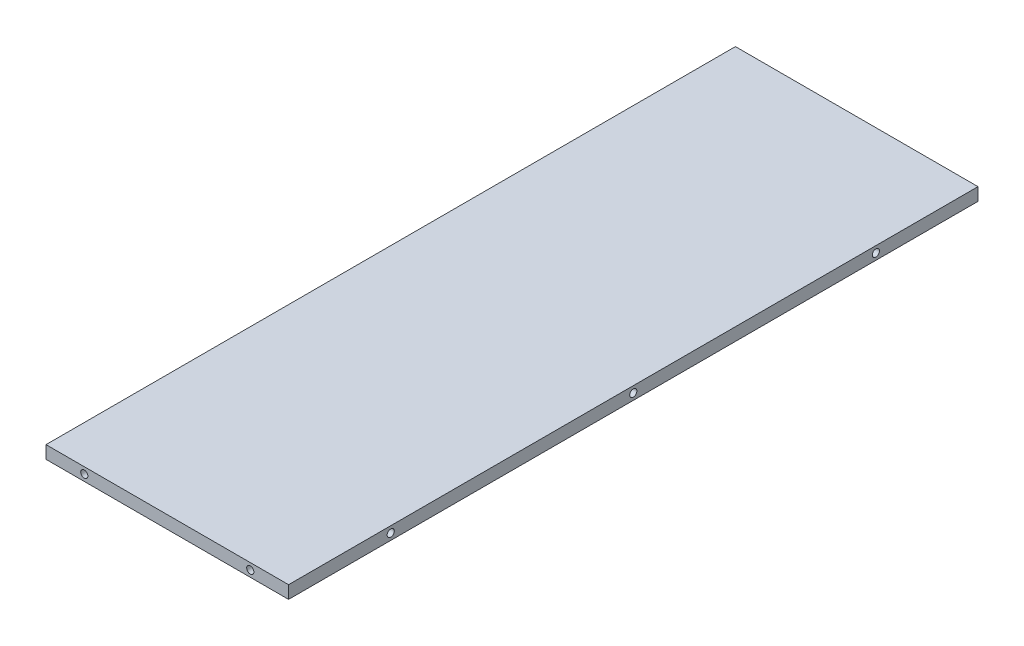
from build123d import *

# Parameters (mm, degrees)
SKETCH1_W                            = 60.325
SKETCH1_H                            = 171.45
EXTRUDE1_DEPTH                       = 3.175
TAP_DRILL_FOR_2_TAP2_D               = 1.778
TAP_DRILL_FOR_2_TAP2_DEPTH           = 6.35
TAP_DRILL_FOR_2_TAP2_TIP             = 0.53416509
TAP_DRILL_FOR_2_TAP4_D               = 1.778
TAP_DRILL_FOR_2_TAP4_DEPTH           = 6.35
TAP_DRILL_FOR_2_TAP4_TIP             = 0.53416509
TAP_DRILL_FOR_2_TAP5_D               = 1.778
TAP_DRILL_FOR_2_TAP5_DEPTH           = 6.35
TAP_DRILL_FOR_2_TAP5_TIP             = 0.53416509
TAP_DRILL_FOR_2_TAP5_ON_FACE_2_D     = 1.778
TAP_DRILL_FOR_2_TAP5_ON_FACE_2_DEPTH = 6.35
TAP_DRILL_FOR_2_TAP5_ON_FACE_2_TIP   = 0.53416509


with BuildPart() as part:
    # Sketch1 → Extrude1 (new body)
    with BuildSketch(Plane(origin=(0, 0, 0), x_dir=(1, 0, 0), z_dir=(0, 1, 0))):
        Rectangle(SKETCH1_W, SKETCH1_H)
    extrude(amount=EXTRUDE1_DEPTH)

    # Tap Drill for #2 Tap2
    with Locations(Plane(origin=(-20.6375, 1.5875, 85.725), x_dir=(1, 0, 0), z_dir=(0, 0, 1))):
        with Locations((0, 0), (41.275, 0)):
            Hole(TAP_DRILL_FOR_2_TAP2_D / 2, depth=TAP_DRILL_FOR_2_TAP2_DEPTH)
            with Locations((0, 0, -(TAP_DRILL_FOR_2_TAP2_DEPTH + TAP_DRILL_FOR_2_TAP2_TIP / 2))):  # 118° drill point
                Cone(0, TAP_DRILL_FOR_2_TAP2_D / 2, TAP_DRILL_FOR_2_TAP2_TIP, mode=Mode.SUBTRACT)

    # Tap Drill for #2 Tap4
    with Locations(Plane(origin=(20.6375, 1.5875, -85.725), x_dir=(-1, 0, 0), z_dir=(0, 0, -1))):
        with Locations((0, 0), (41.275, 0)):
            Hole(TAP_DRILL_FOR_2_TAP4_D / 2, depth=TAP_DRILL_FOR_2_TAP4_DEPTH)
            with Locations((0, 0, -(TAP_DRILL_FOR_2_TAP4_DEPTH + TAP_DRILL_FOR_2_TAP4_TIP / 2))):  # 118° drill point
                Cone(0, TAP_DRILL_FOR_2_TAP4_D / 2, TAP_DRILL_FOR_2_TAP4_TIP, mode=Mode.SUBTRACT)

    # Tap Drill for #2 Tap5
    with Locations(Plane(origin=(-30.1625, 1.5875, -60.325), x_dir=(0, 0, -1), z_dir=(-1, 0, 0))):
        with Locations((0, 0), (-120.65, 0), (-60.325, 0)):
            Hole(TAP_DRILL_FOR_2_TAP5_D / 2, depth=TAP_DRILL_FOR_2_TAP5_DEPTH)
            with Locations((0, 0, -(TAP_DRILL_FOR_2_TAP5_DEPTH + TAP_DRILL_FOR_2_TAP5_TIP / 2))):  # 118° drill point
                Cone(0, TAP_DRILL_FOR_2_TAP5_D / 2, TAP_DRILL_FOR_2_TAP5_TIP, mode=Mode.SUBTRACT)

    # Tap Drill for #2 Tap5 on face 2
    with Locations(Plane(origin=(30.1625, 1.5875, -60.325), x_dir=(0, 0, 1), z_dir=(1, 0, 0))):
        with Locations((0, 0), (120.65, 0), (60.325, 0)):
            Hole(TAP_DRILL_FOR_2_TAP5_ON_FACE_2_D / 2, depth=TAP_DRILL_FOR_2_TAP5_ON_FACE_2_DEPTH)
            with Locations((0, 0, -(TAP_DRILL_FOR_2_TAP5_ON_FACE_2_DEPTH + TAP_DRILL_FOR_2_TAP5_ON_FACE_2_TIP / 2))):  # 118° drill point
                Cone(0, TAP_DRILL_FOR_2_TAP5_ON_FACE_2_D / 2, TAP_DRILL_FOR_2_TAP5_ON_FACE_2_TIP, mode=Mode.SUBTRACT)


solid = part.part
